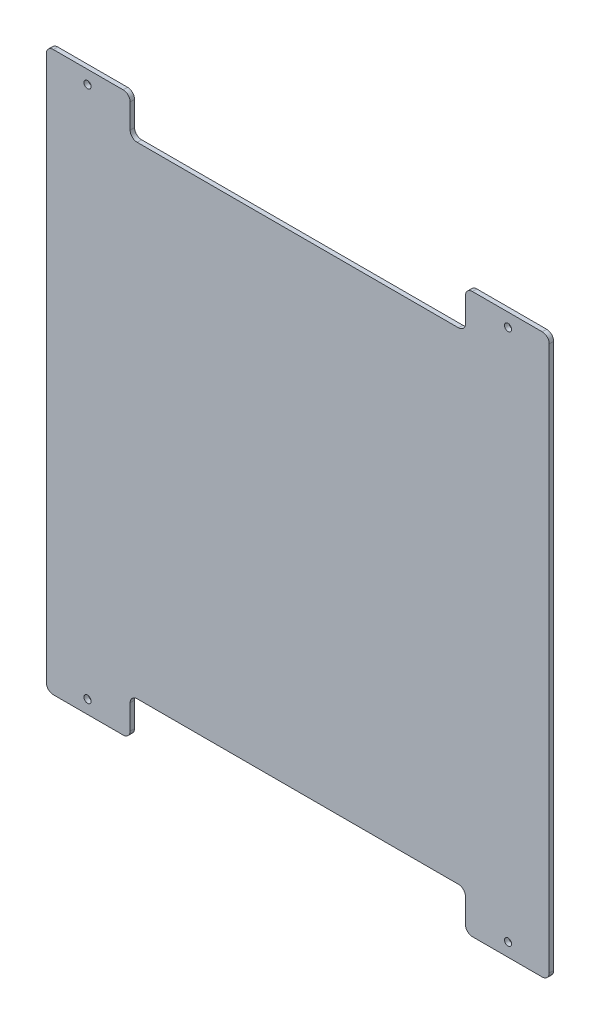
from build123d import *

# Parameters (mm, degrees)
BOSS_EXTRUDE1_DEPTH = 3.175
CUT_EXTRUDE1_REACH  = 5.175
SKETCH2_R           = 2.55


with BuildPart() as part:
    # Model → Boss-Extrude1 (new body)
    with BuildSketch(Plane.XY):
        with BuildLine():
            Line((175, 200), (125, 200))
            ThreePointArc((125, 200), (121.464466094, 198.535533906), (120, 195))
            Line((120, 195), (120, 177.5))
            ThreePointArc((120, 177.5), (118.535533906, 173.964466094), (115, 172.5))
            Line((115, 172.5), (-115, 172.5))
            ThreePointArc((-115, 172.5), (-118.535533906, 173.964466094), (-120, 177.5))
            Line((-120, 177.5), (-120, 195))
            ThreePointArc((-120, 195), (-121.464466094, 198.535533906), (-125, 200))
            Line((-125, 200), (-175, 200))
            ThreePointArc((-175, 200), (-178.535533906, 198.535533906), (-180, 195))
            Line((-180, 195), (-180, -195))
            ThreePointArc((-180, -195), (-178.535533906, -198.535533906), (-175, -200))
            Line((-175, -200), (-125, -200))
            ThreePointArc((-125, -200), (-121.464466094, -198.535533906), (-120, -195))
            Line((-120, -195), (-120, -177.5))
            ThreePointArc((-120, -177.5), (-118.535533906, -173.964466094), (-115, -172.5))
            Line((-115, -172.5), (115, -172.5))
            ThreePointArc((115, -172.5), (118.535533906, -173.964466094), (120, -177.5))
            Line((120, -177.5), (120, -195))
            ThreePointArc((120, -195), (121.464466094, -198.535533906), (125, -200))
            Line((125, -200), (175, -200))
            ThreePointArc((175, -200), (178.535533906, -198.535533906), (180, -195))
            Line((180, -195), (180, 195))
            ThreePointArc((180, 195), (178.535533906, 198.535533906), (175, 200))
        make_face()
    extrude(amount=BOSS_EXTRUDE1_DEPTH)

    # Sketch2 → Cut-Extrude1 (cut, up to next)
    with BuildSketch(Plane.XY.offset(3.175), mode=Mode.PRIVATE) as cut_extrude1_sk1:
        with Locations((-150.5, 190.5)):
            Circle(SKETCH2_R)
    cut_extrude1_tool1 = extrude(cut_extrude1_sk1.sketch, amount=-CUT_EXTRUDE1_REACH, mode=Mode.PRIVATE) & part.part
    add(cut_extrude1_tool1.solids().sort_by_distance((-150.5, 190.5, 3.175))[0], mode=Mode.SUBTRACT)
    # Sketch2 → Cut-Extrude1 (cut, up to next)
    with BuildSketch(Plane.XY.offset(3.175), mode=Mode.PRIVATE) as cut_extrude1_sk2:
        with Locations((-150.5, -190.5)):
            Circle(SKETCH2_R)
    cut_extrude1_tool2 = extrude(cut_extrude1_sk2.sketch, amount=-CUT_EXTRUDE1_REACH, mode=Mode.PRIVATE) & part.part
    add(cut_extrude1_tool2.solids().sort_by_distance((-150.5, -190.5, 3.175))[0], mode=Mode.SUBTRACT)
    # Sketch2 → Cut-Extrude1 (cut, up to next)
    with BuildSketch(Plane.XY.offset(3.175), mode=Mode.PRIVATE) as cut_extrude1_sk3:
        with Locations((150.5, -190.5)):
            Circle(SKETCH2_R)
    cut_extrude1_tool3 = extrude(cut_extrude1_sk3.sketch, amount=-CUT_EXTRUDE1_REACH, mode=Mode.PRIVATE) & part.part
    add(cut_extrude1_tool3.solids().sort_by_distance((150.5, -190.5, 3.175))[0], mode=Mode.SUBTRACT)
    # Sketch2 → Cut-Extrude1 (cut, up to next)
    with BuildSketch(Plane.XY.offset(3.175), mode=Mode.PRIVATE) as cut_extrude1_sk4:
        with Locations((150.5, 190.5)):
            Circle(SKETCH2_R)
    cut_extrude1_tool4 = extrude(cut_extrude1_sk4.sketch, amount=-CUT_EXTRUDE1_REACH, mode=Mode.PRIVATE) & part.part
    add(cut_extrude1_tool4.solids().sort_by_distance((150.5, 190.5, 3.175))[0], mode=Mode.SUBTRACT)


solid = part.part
